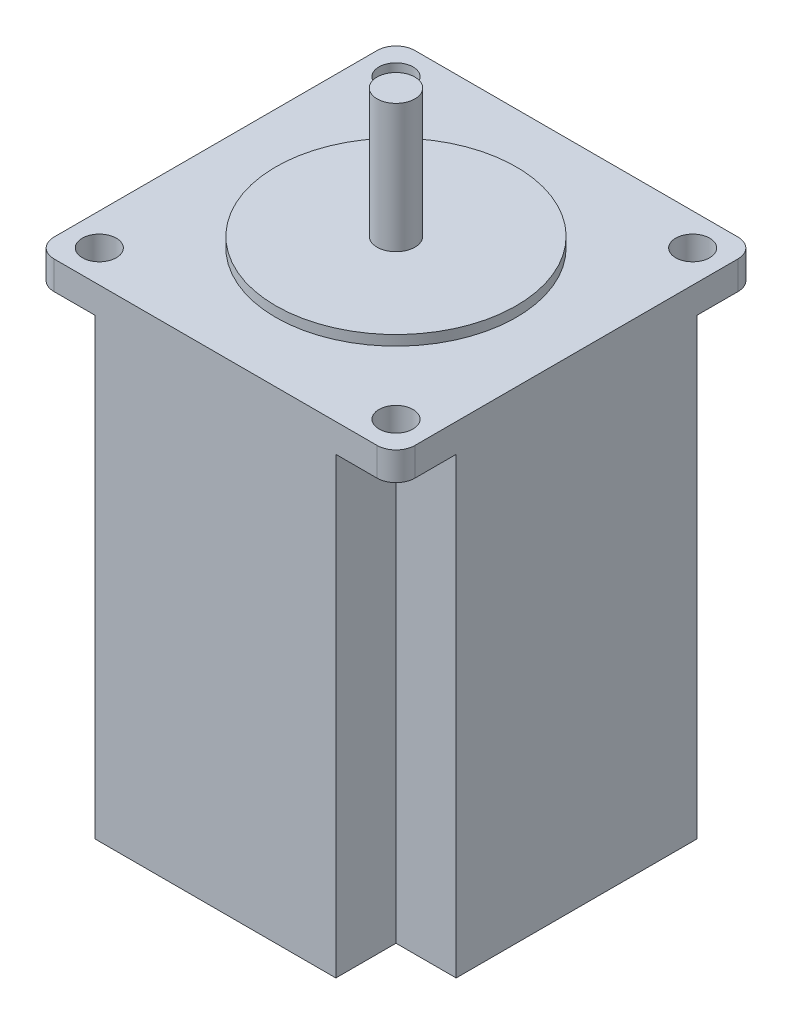
from build123d import *

# Parameters (mm, degrees)
SKETCH1_W               = 57.3
SKETCH1_H               = 57.3
BOSS_EXTRUDE1_DEPTH     = 76.5
SKETCH2_W               = 9.55
SKETCH2_H               = 9.55
CUT_EXTRUDE1_DEPTH      = 72
MIRROR2_COPY_1_SKETCH_W = 9.55
MIRROR2_COPY_1_SKETCH_H = 9.55
MIRROR2_COPY_1_DEPTH    = 72
SKETCH3_R               = 19.1
BOSS_EXTRUDE2_DEPTH     = 1.6
SKETCH4_R               = 3
BOSS_EXTRUDE3_DEPTH     = 20.4
SKETCH5_R               = 2.7
CUT_EXTRUDE2_DEPTH      = 4.5
FILLET2_R               = 3
BOSS_EXTRUDE4_DEPTH     = 1.6
BOSS_EXTRUDE5_DEPTH     = 5.1
SKETCH9_R               = 3
CUT_EXTRUDE3_DEPTH      = 5.1


with BuildPart() as part:
    # Sketch1 → Boss-Extrude1 (new body)
    with BuildSketch(Plane(origin=(0, 0, 0), x_dir=(1, 0, 0), z_dir=(0, 1, 0))):
        Rectangle(SKETCH1_W, SKETCH1_H)
    extrude(amount=BOSS_EXTRUDE1_DEPTH)

    # Sketch2 → Cut-Extrude1 (cut)
    with BuildSketch(Plane.XZ):
        with Locations((-23.875, 23.875)):
            Rectangle(SKETCH2_W, SKETCH2_H)
    cut_extrude1 = extrude(amount=-CUT_EXTRUDE1_DEPTH, mode=Mode.SUBTRACT)

    # Mirror1: Cut-Extrude1 across plane
    add(cut_extrude1.mirror(Plane(origin=(0, 0, 0), x_dir=(0, 0, 1), z_dir=(1, 0, 0))), mode=Mode.SUBTRACT)

    # Mirror2: Cut-Extrude1 across plane
    add(cut_extrude1.mirror(Plane.XY), mode=Mode.SUBTRACT)

    # Mirror2 copy 1 sketch → Mirror2 copy 1 (cut)
    with BuildSketch(Plane(origin=(0, 0, 0), x_dir=(-1, 0, 0), z_dir=(0, -1, 0))):
        with Locations((-23.875, 23.875)):
            Rectangle(MIRROR2_COPY_1_SKETCH_W, MIRROR2_COPY_1_SKETCH_H)
    extrude(amount=-MIRROR2_COPY_1_DEPTH, mode=Mode.SUBTRACT)

    # Sketch3 → Boss-Extrude2 (add)
    with BuildSketch(Plane(origin=(0, 76.5, 0), x_dir=(1, 0, 0), z_dir=(0, 1, 0))):
        Circle(SKETCH3_R)
    extrude(amount=BOSS_EXTRUDE2_DEPTH)

    # Sketch4 → Boss-Extrude3 (add)
    with BuildSketch(Plane(origin=(0, 78.1, 0), x_dir=(1, 0, 0), z_dir=(0, 1, 0))):
        Circle(SKETCH4_R)
    extrude(amount=BOSS_EXTRUDE3_DEPTH)

    # Sketch5 → Cut-Extrude2 (cut)
    with BuildSketch(Plane(origin=(0, 76.5, 0), x_dir=(1, 0, 0), z_dir=(0, 1, 0))):
        with Locations((-23.55, 23.55)):
            Circle(SKETCH5_R)
        with Locations((23.55, 23.55)):
            Circle(SKETCH5_R)
        with Locations((23.55, -23.55)):
            Circle(SKETCH5_R)
        with Locations((-23.55, -23.55)):
            Circle(SKETCH5_R)
    extrude(amount=-CUT_EXTRUDE2_DEPTH, mode=Mode.SUBTRACT)

    # Fillet2
    fillet2_edges = [part.edges().sort_by_distance(p)[0] for p in [
        (-28.65, 74.25, -28.65),
        (28.65, 74.25, -28.65),
        (28.65, 74.25, 28.65),
        (-28.65, 74.25, 28.65),
    ]]
    fillet(fillet2_edges, radius=FILLET2_R)

    # Sketch6 → Boss-Extrude4 (add)
    with BuildSketch(Plane.ZY.offset(28.65)):
        Polygon((0, 0), (5.45, 0), (5.45, 9.6), (-5.45, 9.6), (-5.45, 0), align=None)
    extrude(amount=BOSS_EXTRUDE4_DEPTH)

    # Sketch7 → Boss-Extrude5 (add)
    with BuildSketch(Plane.ZY.offset(30.25)):
        Polygon((0, 0), (-4, 0), (-4, 2), (4, 2), (4, 0), align=None)
    extrude(amount=BOSS_EXTRUDE5_DEPTH)

    # Sketch9 → Cut-Extrude3 (cut)
    with BuildSketch(Plane.XZ):
        Circle(SKETCH9_R)
    extrude(amount=-CUT_EXTRUDE3_DEPTH, mode=Mode.SUBTRACT)


solid = part.part
